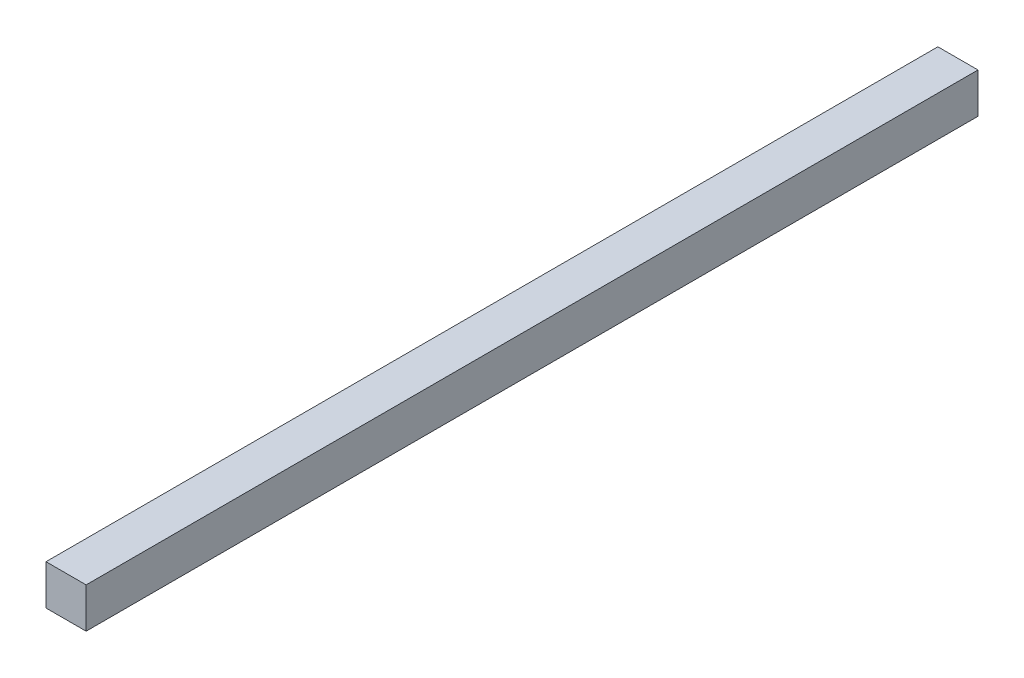
from build123d import *

# Parameters (mm, degrees)
ESQUISSE1_W      = 18
ESQUISSE1_H      = 18
EXTRUSION1_DEPTH = 400


with BuildPart() as part:
    # Esquisse1 → Extrusion1 (new body)
    with BuildSketch(Plane.XY):
        with Locations((9, 9)):
            Rectangle(ESQUISSE1_W, ESQUISSE1_H)
    extrude(amount=-EXTRUSION1_DEPTH)


solid = part.part
